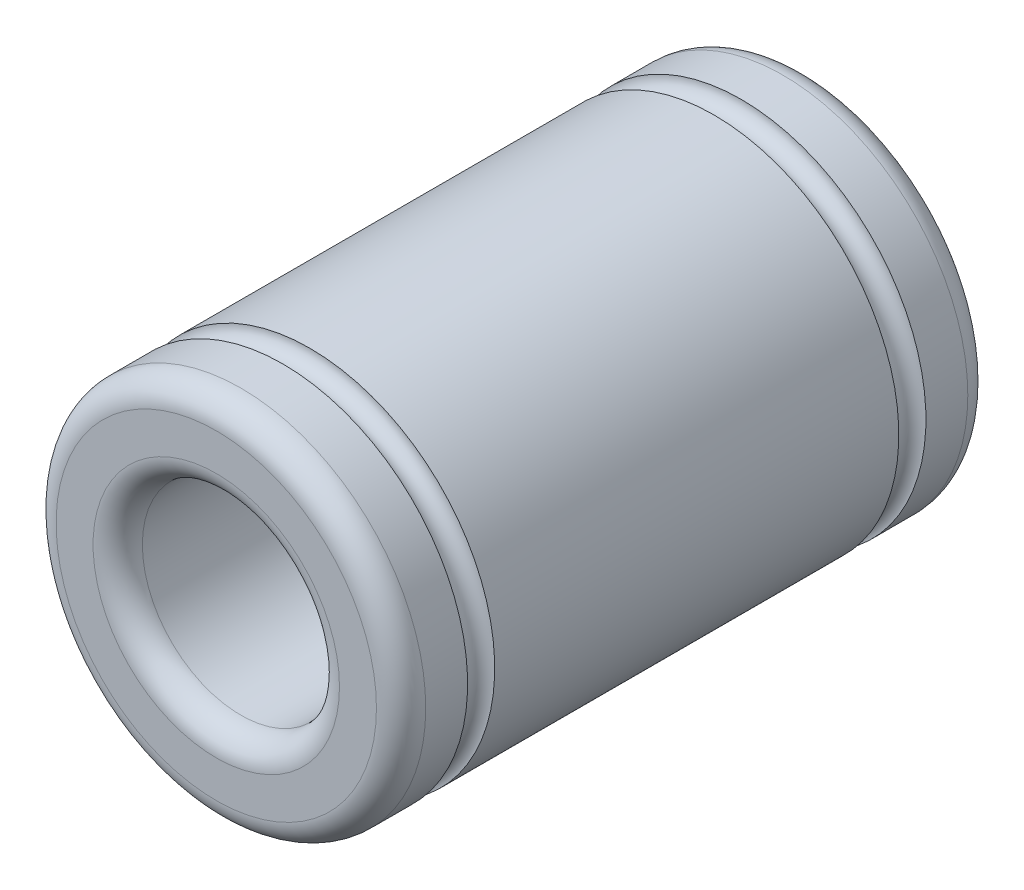
from build123d import *

# Parameters (mm, degrees)
SKETCH1_R           = 7.5
SKETCH1_R_2         = 4
BOSS_EXTRUDE1_DEPTH = 24
FILLET1_R           = 1
SKETCH2_R           = 0.55


with BuildPart() as part:
    # Sketch1 → Boss-Extrude1 (new body)
    with BuildSketch(Plane.XY):
        Circle(SKETCH1_R)
        Circle(SKETCH1_R_2, mode=Mode.SUBTRACT)
    extrude(amount=BOSS_EXTRUDE1_DEPTH)

    # Fillet1
    fillet1_edges = [part.edges().sort_by_distance(p)[0] for p in [
        (-7.5, 0, 0),
        (-7.5, 0, 24),
        (-4, 0, 0),
        (-4, 0, 24),
    ]]
    fillet(fillet1_edges, radius=FILLET1_R)

    # Sketch2 → Cut-Revolve1 (revolve, cut)
    with BuildSketch(Plane(origin=(0, 0, 0), x_dir=(0, 0, -1), z_dir=(1, 0, 0))):
        with Locations((-20.75, 7.5)):
            Circle(SKETCH2_R)
        with Locations((-3.25, 7.5)):
            Circle(SKETCH2_R)
    revolve(axis=Axis((0, 0, 24), (0, 0, -1)), mode=Mode.SUBTRACT)


solid = part.part
